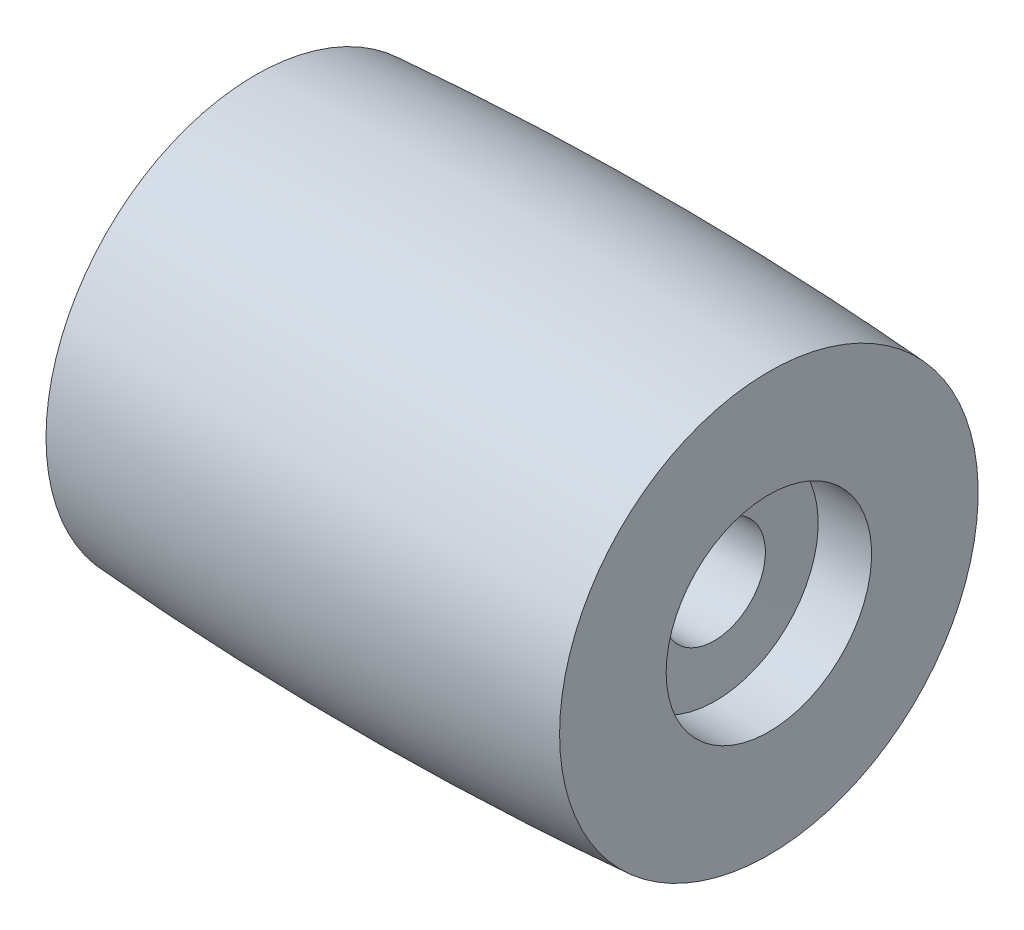
from build123d import *


with BuildPart() as part:
    # Sketch1 → Revolve1 (revolve)
    with BuildSketch(Plane.XY):
        with BuildLine():
            Line((0, 8.15), (0, 4))
            Line((0, 4), (2.081081081, 4))
            Line((2.081081081, 4), (2.081081081, 2))
            Line((2.081081081, 2), (17.864864865, 2))
            Line((17.864864865, 2), (17.918918919, 4))
            Line((17.918918919, 4), (20, 4))
            Line((20, 4), (20, 8.15))
            ThreePointArc((20, 8.15), (10, 8.483704529), (0, 8.15))
        make_face()
    revolve(axis=Axis((0, 0, 0), (1, 0, 0)))


solid = part.part
